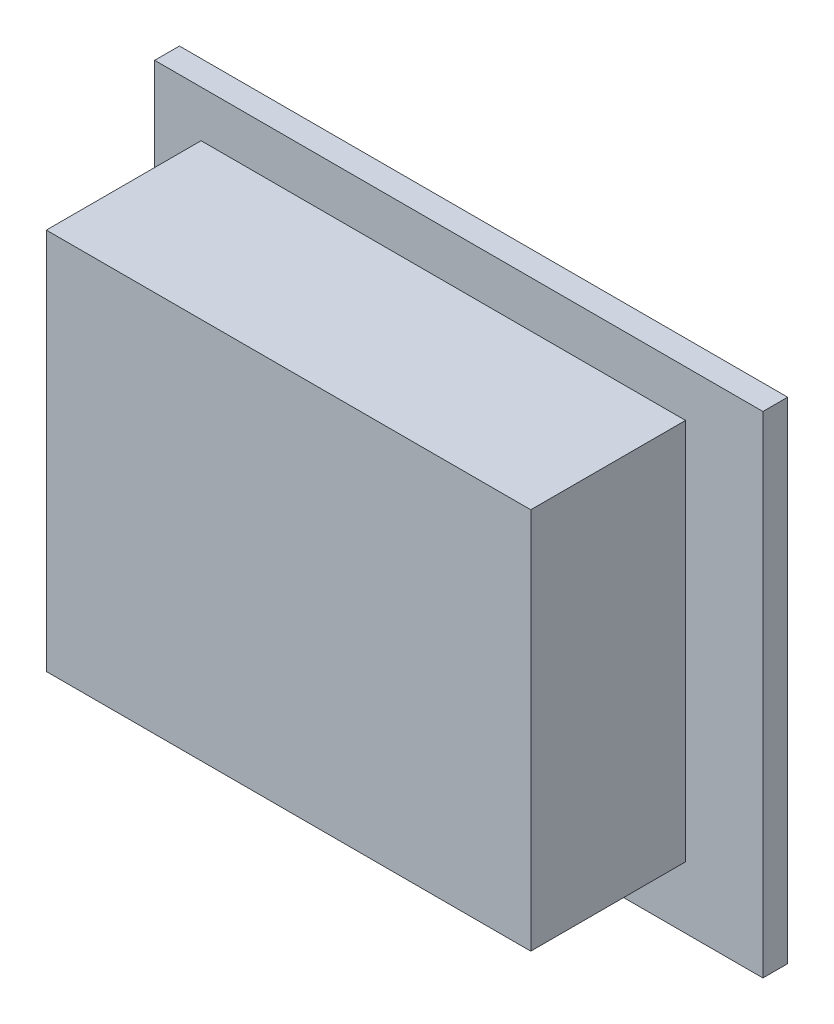
from build123d import *

# Parameters (mm, degrees)
ESQUISSE1_W        = 39.3
ESQUISSE1_H        = 31.7
BOSS_EXTRU_1_DEPTH = 1.6
ESQUISSE2_W        = 31.3
ESQUISSE2_H        = 24.7
BOSS_EXTRU_2_DEPTH = 10


with BuildPart() as part:
    # Esquisse1 → Boss.-Extru.1 (new body)
    with BuildSketch(Plane.XY):
        with Locations((19.65, 15.85)):
            Rectangle(ESQUISSE1_W, ESQUISSE1_H)
    extrude(amount=BOSS_EXTRU_1_DEPTH)

    # Esquisse2 → Boss.-Extru.2 (add)
    with BuildSketch(Plane.XY.offset(1.6)):
        with Locations((18.65, 16.35)):
            Rectangle(ESQUISSE2_W, ESQUISSE2_H)
    extrude(amount=BOSS_EXTRU_2_DEPTH)


solid = part.part
